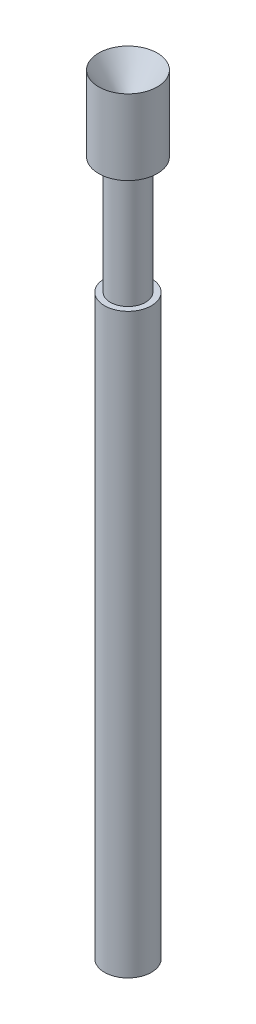
from build123d import *


with BuildPart() as part:
    # Sketch1 → Revolve1 (revolve)
    with BuildSketch(Plane.XY):
        Polygon((0, 0), (0.508, 0), (0.508, 12.4968), (0.381, 12.4968), (0.381, 15.0368), (0.635, 15.0368), (0.635, 16.6624), (0.127, 15.9004), (0, 15.9004), align=None)
    revolve(axis=Axis((0, 18.285593004, 0), (0, -1, 0)))


solid = part.part
